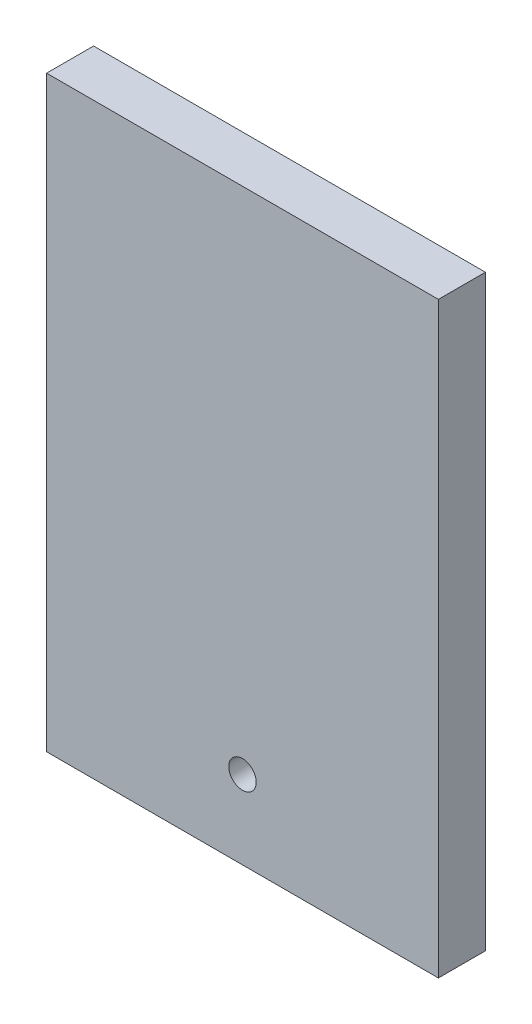
from build123d import *

# Parameters (mm, degrees)
SKETCH1_W           = 50.8
SKETCH1_H           = 76.2
BOSS_EXTRUDE1_DEPTH = 6.096
SKETCH2_R           = 1.778
CUT_EXTRUDE1_DEPTH  = 7.096


with BuildPart() as part:
    # Sketch1 → Boss-Extrude1 (new body)
    with BuildSketch(Plane.XY):
        with Locations((25.4, 38.1)):
            Rectangle(SKETCH1_W, SKETCH1_H)
    extrude(amount=BOSS_EXTRUDE1_DEPTH)

    # Sketch2 → Cut-Extrude1 (cut, through all)
    with BuildSketch(Plane(origin=(0, 0, 0), x_dir=(-1, 0, 0), z_dir=(0, 0, -1))):
        with Locations((-25.4, 10.16)):
            Circle(SKETCH2_R)
    extrude(amount=-CUT_EXTRUDE1_DEPTH, mode=Mode.SUBTRACT)


solid = part.part
